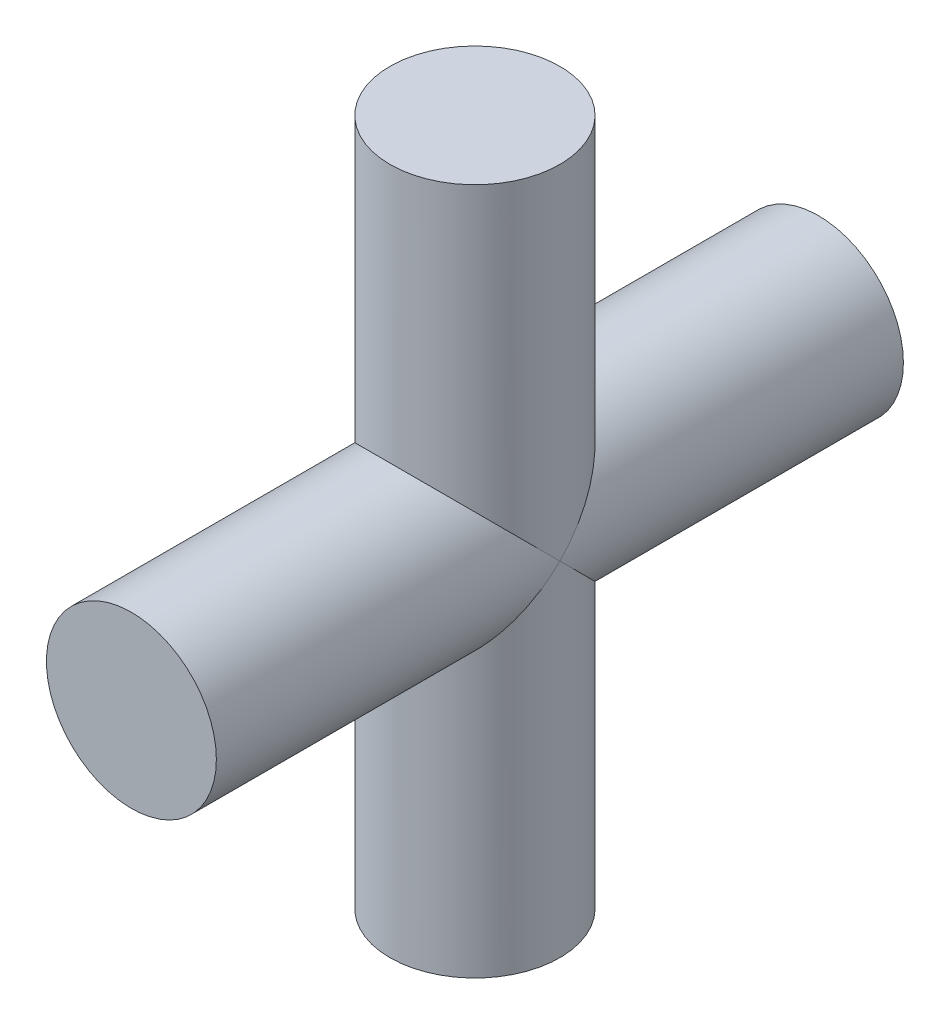
from build123d import *

# Parameters (mm, degrees)
BOSS_EXTRUDE1_DEPTH      = 19
BOSS_EXTRUDE1_DEPTH_BACK = 19
SKETCH1_R                = 4.7
BOSS_EXTRUDE2_DEPTH      = 19
BOSS_EXTRUDE2_DEPTH_BACK = 19
SKETCH2_R                = 4.7


with BuildPart() as part:
    # Sketch1 → Boss-Extrude1 (new, two sides: drawn at the far end of the back side and taken through both)
    with BuildSketch(Plane.XY.offset(-BOSS_EXTRUDE1_DEPTH_BACK)):
        Circle(SKETCH1_R)
    extrude(amount=BOSS_EXTRUDE1_DEPTH + BOSS_EXTRUDE1_DEPTH_BACK)

    # Sketch2 → Boss-Extrude2 (add, two sides: drawn at the far end of the back side and taken through both)
    with BuildSketch(Plane(origin=(0, 0, 0), x_dir=(1, 0, 0), z_dir=(0, 1, 0)).offset(-BOSS_EXTRUDE2_DEPTH_BACK)):
        Circle(SKETCH2_R)
    extrude(amount=BOSS_EXTRUDE2_DEPTH + BOSS_EXTRUDE2_DEPTH_BACK)


solid = part.part
